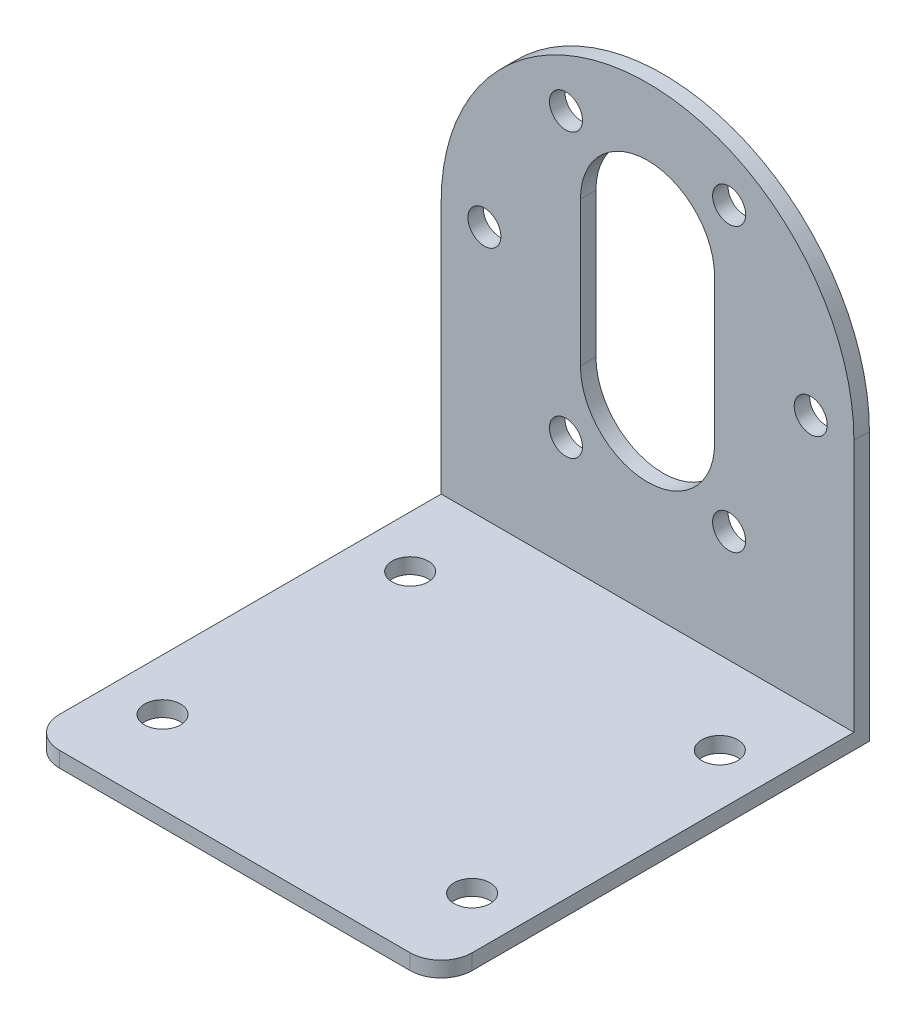
from build123d import *

# Parameters (mm, degrees)
SKETCH1_W           = 40
SKETCH1_H           = 40
SKETCH1_R           = 1.75
BOSS_EXTRUDE1_DEPTH = 1.5
FILLET1_R           = 3
SKETCH2_R           = 1.6
BOSS_EXTRUDE2_DEPTH = 1.5


with BuildPart() as part:
    # Sketch1 → Boss-Extrude1 (new body)
    with BuildSketch(Plane(origin=(0, 0, 0), x_dir=(1, 0, 0), z_dir=(0, 1, 0))):
        Rectangle(SKETCH1_W, SKETCH1_H)
        with Locations((-15, -12)):
            Circle(SKETCH1_R, mode=Mode.SUBTRACT)
        with Locations((15, -12)):
            Circle(SKETCH1_R, mode=Mode.SUBTRACT)
        with Locations((15, 12)):
            Circle(SKETCH1_R, mode=Mode.SUBTRACT)
        with Locations((-15, 12)):
            Circle(SKETCH1_R, mode=Mode.SUBTRACT)
    extrude(amount=BOSS_EXTRUDE1_DEPTH)

    # Fillet1
    fillet1_edges = [part.edges().sort_by_distance(p)[0] for p in [
        (20, 0.75, 20),
        (-20, 0.75, 20),
    ]]
    fillet(fillet1_edges, radius=FILLET1_R)

    # Sketch2 → Boss-Extrude2 (add)
    with BuildSketch(Plane(origin=(0, 0, -20), x_dir=(-1, 0, 0), z_dir=(0, 0, -1))):
        with BuildLine():
            Line((-20, 0), (20, 0))
            Line((20, 0), (20, 26))
            ThreePointArc((20, 26), (0, 46), (-20, 26))
            Line((-20, 26), (-20, 0))
        make_face()
        with Locations((15.81171166, 26)):
            Circle(SKETCH2_R, mode=Mode.SUBTRACT)
        with Locations((7.90585583, 12.306656025)):
            Circle(SKETCH2_R, mode=Mode.SUBTRACT)
        with Locations((-7.90585583, 12.306656025)):
            Circle(SKETCH2_R, mode=Mode.SUBTRACT)
        with Locations((-15.81171166, 26)):
            Circle(SKETCH2_R, mode=Mode.SUBTRACT)
        with Locations((-7.90585583, 39.693343975)):
            Circle(SKETCH2_R, mode=Mode.SUBTRACT)
        with Locations((7.90585583, 39.693343975)):
            Circle(SKETCH2_R, mode=Mode.SUBTRACT)
        with BuildLine():
            Line((-6.5, 33), (-6.5, 19))
            ThreePointArc((-6.5, 19), (0, 12.5), (6.5, 19))
            Line((6.5, 19), (6.5, 33))
            ThreePointArc((6.5, 33), (0, 39.5), (-6.5, 33))
        make_face(mode=Mode.SUBTRACT)
    extrude(amount=BOSS_EXTRUDE2_DEPTH)


solid = part.part
